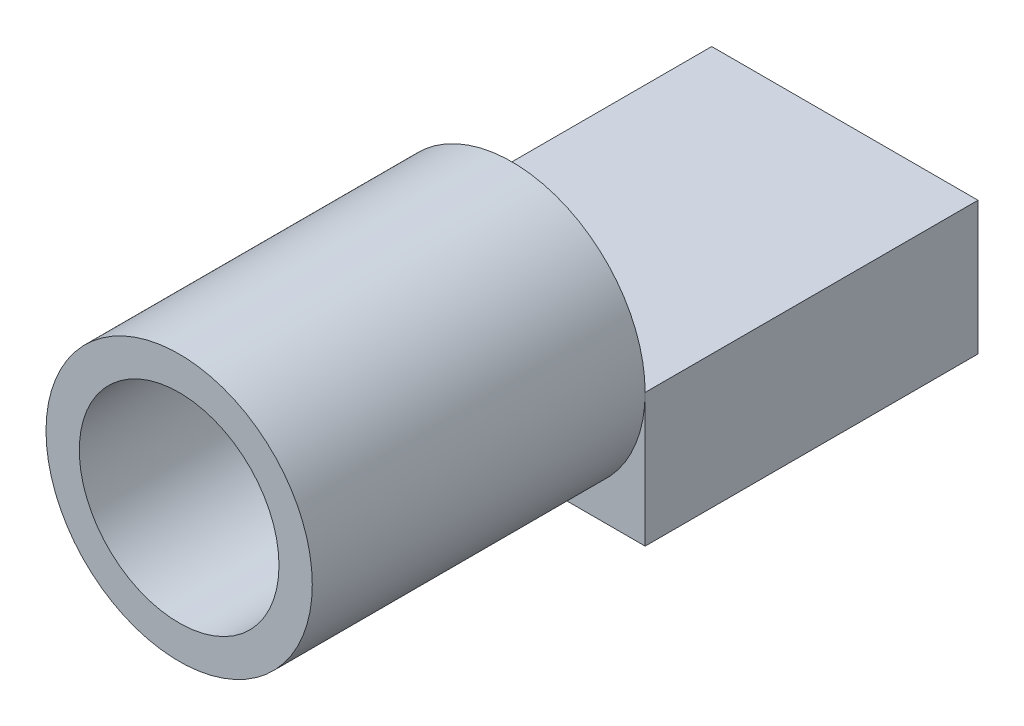
from build123d import *

# Parameters (mm, degrees)
ESBO_O1_R                = 4
ESBO_O1_R_2              = 3
RESSALTO_EXTRUS_O1_DEPTH = 10
ESBO_O2_W                = 8
ESBO_O2_H                = 4
RESSALTO_EXTRUS_O2_DEPTH = 10


with BuildPart() as part:
    # Esboço1 → Ressalto-extrusão1 (new body)
    with BuildSketch(Plane.XY):
        Circle(ESBO_O1_R)
        Circle(ESBO_O1_R_2, mode=Mode.SUBTRACT)
    extrude(amount=RESSALTO_EXTRUS_O1_DEPTH)

    # Esboço2 → Ressalto-extrusão2 (add)
    with BuildSketch(Plane(origin=(0, 0, 0), x_dir=(-1, 0, 0), z_dir=(0, 0, -1))):
        with Locations((0, -2)):
            Rectangle(ESBO_O2_W, ESBO_O2_H)
    extrude(amount=RESSALTO_EXTRUS_O2_DEPTH)


solid = part.part
